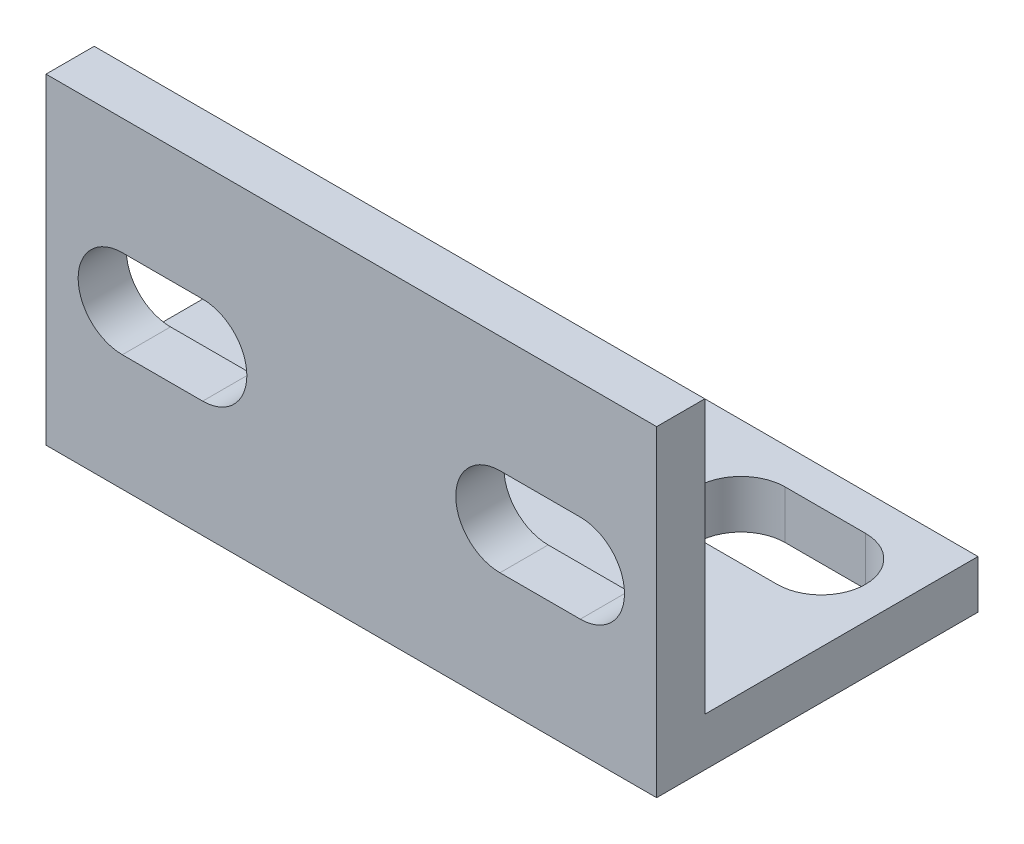
from build123d import *

# Parameters (mm, degrees)
BOSS_EXTRUDE1_DEPTH = 38
CUT_EXTRUDE1_DEPTH  = 4
CUT_EXTRUDE2_DEPTH  = 4


with BuildPart() as part:
    # Sketch1 → Boss-Extrude1 (new body)
    with BuildSketch(Plane(origin=(0, 0, 0), x_dir=(0, 0, -1), z_dir=(1, 0, 0))):
        Polygon((0, 20), (0, 0), (20, 0), (20, 3), (3, 3), (3, 20), align=None)
    extrude(amount=-BOSS_EXTRUDE1_DEPTH)

    # Sketch2 → Cut-Extrude1 (cut, through all)
    with BuildSketch(Plane(origin=(0, 0, -3), x_dir=(-1, 0, 0), z_dir=(0, 0, -1))):
        with BuildLine():
            Line((4.75, 12.75), (9.75, 12.75))
            ThreePointArc((9.75, 12.75), (12.5, 10), (9.75, 7.25))
            Line((9.75, 7.25), (4.75, 7.25))
            ThreePointArc((4.75, 7.25), (2, 10), (4.75, 12.75))
        make_face()
    cut_extrude1 = extrude(amount=-CUT_EXTRUDE1_DEPTH, mode=Mode.SUBTRACT)

    # Sketch3 → Cut-Extrude2 (cut, through all)
    with BuildSketch(Plane(origin=(0, 3, 0), x_dir=(1, 0, 0), z_dir=(0, 1, 0))):
        with BuildLine():
            Line((-4.75, 12.25), (-9.75, 12.25))
            ThreePointArc((-9.75, 12.25), (-12.5, 15), (-9.75, 17.75))
            Line((-9.75, 17.75), (-4.75, 17.75))
            ThreePointArc((-4.75, 17.75), (-2, 15), (-4.75, 12.25))
        make_face()
    cut_extrude2 = extrude(amount=-CUT_EXTRUDE2_DEPTH, mode=Mode.SUBTRACT)

    # Mirror1: Cut-Extrude1 across plane
    add(cut_extrude1.mirror(Plane(origin=(-19, 0, 0), x_dir=(0, 0, 1), z_dir=(1, 0, 0))), mode=Mode.SUBTRACT)

    # Mirror2: Cut-Extrude2 across plane
    add(cut_extrude2.mirror(Plane(origin=(-19, 0, 0), x_dir=(0, 0, 1), z_dir=(1, 0, 0))), mode=Mode.SUBTRACT)


solid = part.part
